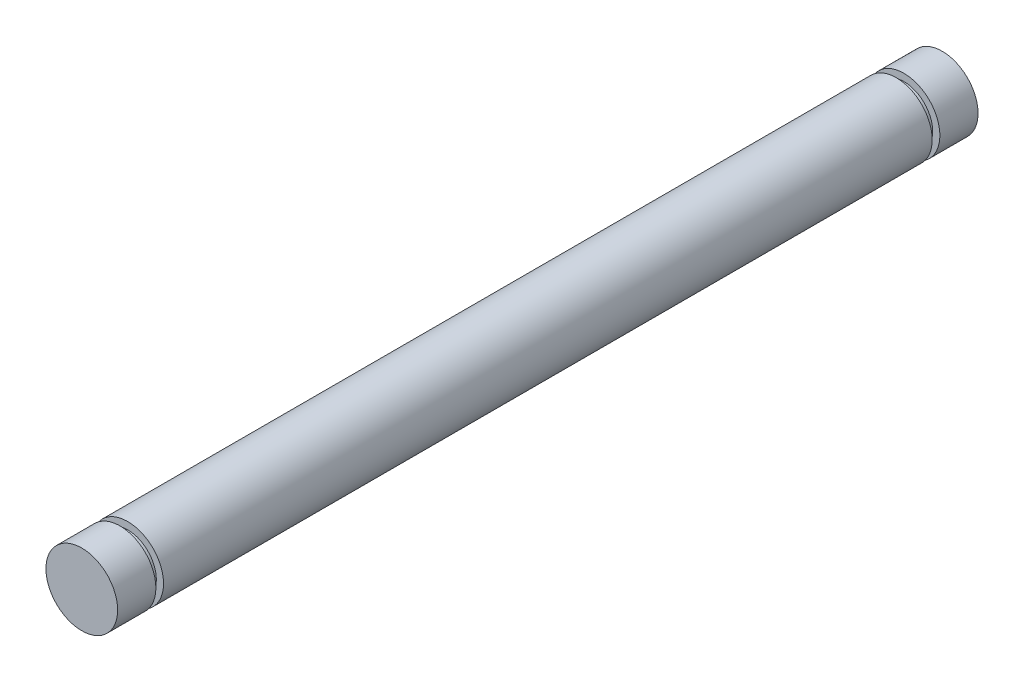
from build123d import *

# Parameters (mm, degrees)
SKETCH1_R           = 4.7625
BOSS_EXTRUDE1_DEPTH = 102.108
SKETCH2_R           = 3.81
BOSS_EXTRUDE2_DEPTH = 1.016
SKETCH3_R           = 4.7625
BOSS_EXTRUDE3_DEPTH = 5.08
SKETCH4_R           = 3.81
BOSS_EXTRUDE4_DEPTH = 1.016
SKETCH5_R           = 4.7625
BOSS_EXTRUDE5_DEPTH = 5.08


with BuildPart() as part:
    # Sketch1 → Boss-Extrude1 (new body)
    with BuildSketch(Plane.XY):
        Circle(SKETCH1_R)
    extrude(amount=BOSS_EXTRUDE1_DEPTH)

    # Sketch2 → Boss-Extrude2 (add)
    with BuildSketch(Plane(origin=(0, 0, 0), x_dir=(-1, 0, 0), z_dir=(0, 0, -1))):
        Circle(SKETCH2_R)
    extrude(amount=BOSS_EXTRUDE2_DEPTH)

    # Sketch3 → Boss-Extrude3 (add)
    with BuildSketch(Plane(origin=(0, 0, -1.016), x_dir=(-1, 0, 0), z_dir=(0, 0, -1))):
        Circle(SKETCH3_R)
    extrude(amount=BOSS_EXTRUDE3_DEPTH)

    # Sketch4 → Boss-Extrude4 (add)
    with BuildSketch(Plane.XY.offset(102.108)):
        Circle(SKETCH4_R)
    extrude(amount=BOSS_EXTRUDE4_DEPTH)

    # Sketch5 → Boss-Extrude5 (add)
    with BuildSketch(Plane.XY.offset(103.124)):
        Circle(SKETCH5_R)
    extrude(amount=BOSS_EXTRUDE5_DEPTH)


solid = part.part
